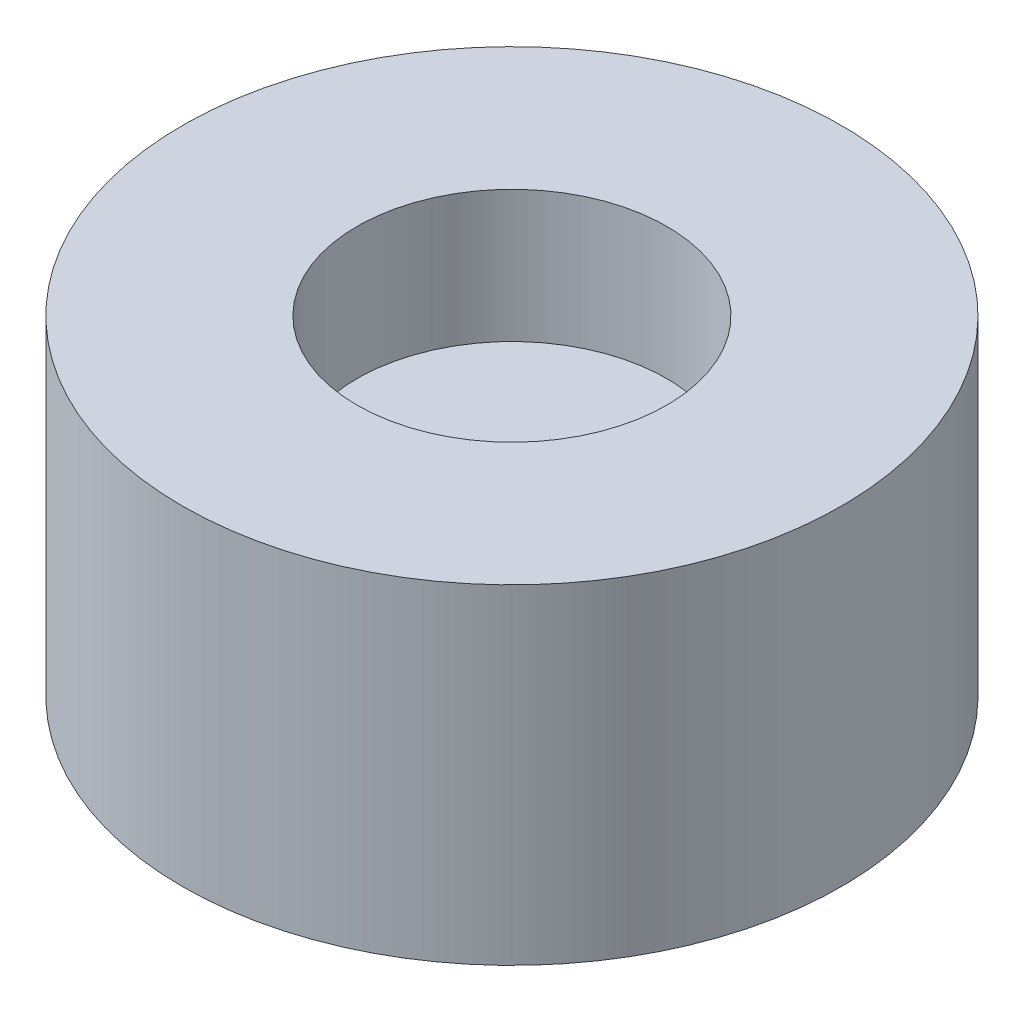
from build123d import *

# Parameters (mm, degrees)
SKETCH1_R           = 12.7
BOSS_EXTRUDE1_DEPTH = 12.7
SKETCH2_R           = 5.969
CUT_EXTRUDE1_DEPTH  = 5.08


with BuildPart() as part:
    # Sketch1 → Boss-Extrude1 (new body)
    with BuildSketch(Plane(origin=(0, 0, 0), x_dir=(1, 0, 0), z_dir=(0, 1, 0))):
        with Locations(Location((0, 0, 0), (0, 0, 270))):  # turned: the seam where the file's is
            Circle(SKETCH1_R)
    extrude(amount=BOSS_EXTRUDE1_DEPTH)

    # Sketch2 → Cut-Extrude1 (cut)
    with BuildSketch(Plane(origin=(0, 12.7, 0), x_dir=(1, 0, 0), z_dir=(0, 1, 0))):
        with Locations(Location((0, 0, 0), (0, 0, 270))):  # turned: the seam where the file's is
            Circle(SKETCH2_R)
    extrude(amount=-CUT_EXTRUDE1_DEPTH, mode=Mode.SUBTRACT)


solid = part.part
